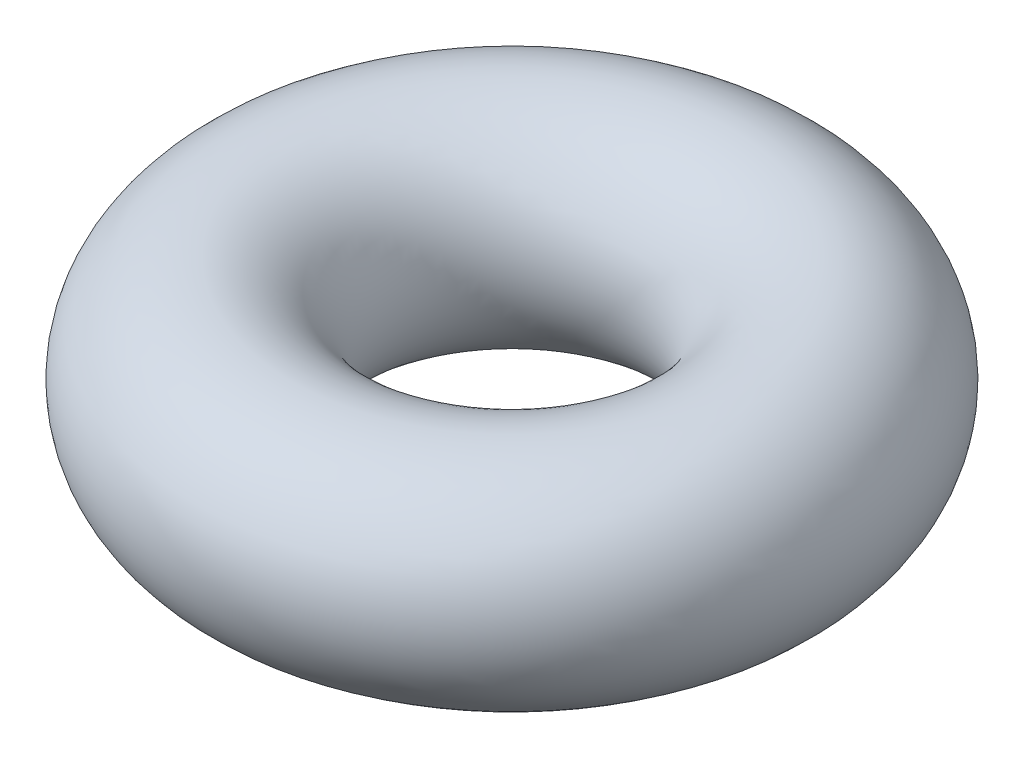
from build123d import *

# Parameters (mm, degrees)
SKETCH1_R = 0.95


with BuildPart() as part:
    # Sketch1 → Revolve1 (revolve)
    with BuildSketch(Plane.XY):
        with Locations((1.975, 0)):
            Circle(SKETCH1_R)
    revolve(axis=Axis((0, 0, 0), (0, 1, 0)))


solid = part.part
